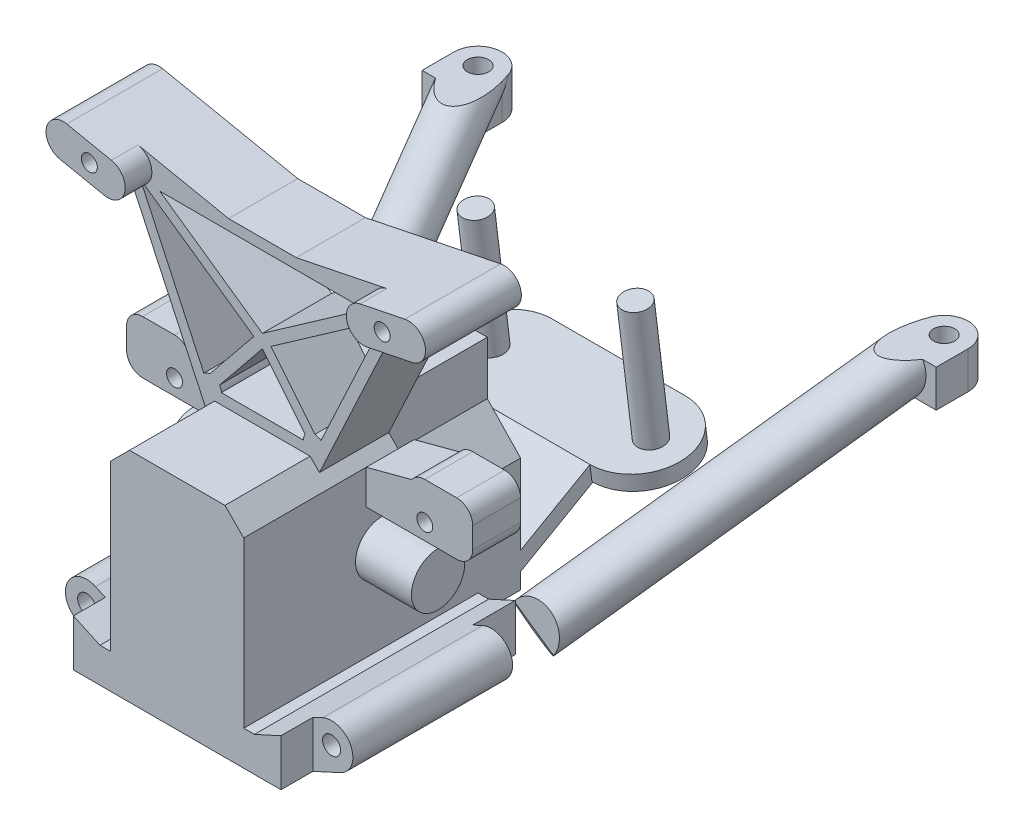
from build123d import *

# Parameters (mm, degrees)
SKETCH1_R                    = 5
DRIVELINE_AXIS_DEPTH         = 23
DUMMY_BOSS_DEPTH             = 26
PIN_BASE_DEPTH               = 44
PIN_HOLES_D                  = 3.4
SKETCH8_R                    = 1.5
UPRIGHTS_DEPTH               = 10
UPRIGHTS_DEPTH_BACK          = 3
SKETCH9_R                    = 1.5
SHOCK_MOUNT_DEPTH            = 5
SHOCK_MOUNT_DEPTH_BACK       = 13
SKETCH10_R                   = 1.5
TURNBUCKLE_MOUNTS_DEPTH      = 3
TURNBUCKLE_MOUNTS_DEPTH_BACK = 6
TURNBUCKLE_ROOM_DEPTH        = 1
TURNBUCKLE_ROOM_DEPTH_BACK   = 23
ARM_PROFILE_R                = 4.5
CHASSIS_MOUNT_DEPTH          = 7
SKETCH29_W                   = 17.866942734
SKETCH29_H                   = 5.34009454
TRIM_DEPTH                   = 50
SKETCH30_R                   = 2
CHASSIS_HOLES_DEPTH          = 7
BOSS_EXTRUDE2_DEPTH          = 12.5
BOSS_EXTRUDE3_DEPTH          = 3
SKETCH43_R                   = 2.5
BOSS_EXTRUDE4_DEPTH          = 24
SKETCH45_W                   = 10.988682225
SKETCH45_H                   = 8
CUT_EXTRUDE5_DEPTH           = 14


with BuildPart() as part:
    # Sketch1 → Driveline Axis (new body, symmetric)
    with BuildSketch(Plane(origin=(0, 0, 0), x_dir=(0, 0, -1), z_dir=(1, 0, 0))):
        Circle(SKETCH1_R)
    extrude(amount=DRIVELINE_AXIS_DEPTH, both=True)

    # Sketch2 → Dummy Boss (add, symmetric)
    with BuildSketch(Plane.XY):
        Polygon((-12.5, -20), (-12.5, 14.464466094), (-8.964466094, 18), (8.964466094, 18), (12.5, 14.464466094), (12.5, -20), align=None)
    extrude(amount=DUMMY_BOSS_DEPTH, both=True)

    # Sketch3 → Pin Base (add)
    with BuildSketch(Plane(origin=(0, 0, -18), x_dir=(-1, 0, 0), z_dir=(0, 0, -1))):
        with BuildLine():
            Line((-19.5, -23), (19.5, -23))
            Line((19.5, -23), (24.664120213, -20.637403458))
            ThreePointArc((24.664120213, -20.637403458), (26.637403458, -15.335879787), (21.335879787, -13.362596542))
            Line((21.335879787, -13.362596542), (14.5, -16.490026826))
            Line((14.5, -16.490026826), (12.5, -16.490026826))
            Line((12.5, -16.490026826), (12.5, -20))
            Line((12.5, -20), (-12.5, -20))
            Line((-12.5, -20), (-12.5, -16.490026826))
            Line((-12.5, -16.490026826), (-14.5, -16.490026826))
            Line((-14.5, -16.490026826), (-21.335879787, -13.362596542))
            ThreePointArc((-21.335879787, -13.362596542), (-26.637403458, -15.335879787), (-24.664120213, -20.637403458))
            Line((-24.664120213, -20.637403458), (-19.5, -23))
        make_face()
    extrude(amount=-PIN_BASE_DEPTH)

    # Pin Holes (through all)
    with Locations(Plane(origin=(0, 0, -18), x_dir=(-1, 0, 0), z_dir=(0, 0, -1))):
        with Locations((-23, -17), (23, -17)):
            Hole(PIN_HOLES_D / 2)

    # Sketch8 → Uprights (add, two sides)
    with BuildSketch(Plane.XY) as uprights_sk:
        with BuildLine():
            Line((-10.732233047, 16.232233047), (-24.661465898, 46.103569293))
            Line((-24.661465898, 46.103569293), (-33.048979486, 47.815663334))
            ThreePointArc((-33.048979486, 47.815663334), (-35.583316151, 51.65), (-31.748979486, 54.184336666))
            Line((-31.748979486, 54.184336666), (-6.351020514, 49))
            Line((-6.351020514, 49), (6.351020514, 49))
            Line((6.351020514, 49), (31.748979486, 54.184336666))
            ThreePointArc((31.748979486, 54.184336666), (35.583316151, 51.65), (33.048979486, 47.815663334))
            Line((33.048979486, 47.815663334), (24.661465898, 46.103569293))
            Line((24.661465898, 46.103569293), (10.732233047, 16.232233047))
            Line((10.732233047, 16.232233047), (8.964466094, 18))
            Line((8.964466094, 18), (-8.964466094, 18))
            Line((-8.964466094, 18), (-10.732233047, 16.232233047))
        make_face()
        with Locations((-27.5, 50)):
            Circle(SKETCH8_R, mode=Mode.SUBTRACT)
        with Locations((27.5, 50)):
            Circle(SKETCH8_R, mode=Mode.SUBTRACT)
        with BuildLine():
            Line((9.866245938, 21.994232403), (1.612099151, 32.1872548))
            Line((1.612099151, 32.1872548), (22.924030195, 47.110029571))
            Line((22.924030195, 47.110029571), (10.997739753, 21.534017182))
            ThreePointArc((10.997739753, 21.534017182), (10.467987263, 21.852621345), (9.866245938, 21.994232403))
        make_face(mode=Mode.SUBTRACT)
        with BuildLine():
            Line((7.714466094, 20), (-7.714466094, 20))
            ThreePointArc((-7.714466094, 20), (-7.795487149, 20.563488959), (-8.031985901, 21.081323449))
            Line((-8.031985901, 21.081323449), (0, 31))
            Line((0, 31), (8.031985901, 21.081323449))
            ThreePointArc((8.031985901, 21.081323449), (7.795487149, 20.563488959), (7.714466094, 20))
        make_face(mode=Mode.SUBTRACT)
        with BuildLine():
            Line((-10.997739753, 21.534017182), (-22.924030195, 47.110029571))
            Line((-22.924030195, 47.110029571), (-1.612099151, 32.1872548))
            Line((-1.612099151, 32.1872548), (-9.866245938, 21.994232403))
            ThreePointArc((-9.866245938, 21.994232403), (-10.467987263, 21.852621345), (-10.997739753, 21.534017182))
        make_face(mode=Mode.SUBTRACT)
        Polygon((-19.279998091, 47), (0, 33.5), (19.279998091, 47), align=None, mode=Mode.SUBTRACT)
    extrude(amount=UPRIGHTS_DEPTH)
    extrude(uprights_sk.sketch, amount=-UPRIGHTS_DEPTH_BACK)

    # Sketch9 → Shock Mount (add, two sides)
    with BuildSketch(Plane.XY.offset(10)) as shock_mount_sk:
        with BuildLine():
            Line((-24.661465898, 46.103569293), (-33.048979486, 47.815663334))
            ThreePointArc((-33.048979486, 47.815663334), (-35.583316151, 51.65), (-31.748979486, 54.184336666))
            Line((-31.748979486, 54.184336666), (-23.361465898, 52.472242624))
            ThreePointArc((-23.361465898, 52.472242624), (-20.827129232, 48.637905958), (-24.661465898, 46.103569293))
        make_face()
        with Locations((-27.5, 50)):
            Circle(SKETCH9_R, mode=Mode.SUBTRACT)
        with BuildLine():
            Line((23.361465898, 52.472242624), (31.748979486, 54.184336666))
            ThreePointArc((31.748979486, 54.184336666), (35.583316151, 51.65), (33.048979486, 47.815663334))
            Line((33.048979486, 47.815663334), (24.661465898, 46.103569293))
            ThreePointArc((24.661465898, 46.103569293), (20.827129232, 48.637905958), (23.361465898, 52.472242624))
        make_face()
        with Locations((27.5, 50)):
            Circle(SKETCH9_R, mode=Mode.SUBTRACT)
    extrude(amount=SHOCK_MOUNT_DEPTH)
    extrude(shock_mount_sk.sketch, amount=-SHOCK_MOUNT_DEPTH_BACK)

    # Sketch10 → Turnbuckle Mounts (add, two sides)
    with BuildSketch(Plane.XY) as turnbuckle_mounts_sk:
        with BuildLine():
            Line((29.5, 8), (12.5, 8))
            Line((12.5, 8), (12.5, 14.464466094))
            Line((12.5, 14.464466094), (21.055616084, 16.739249053))
            ThreePointArc((21.055616084, 16.739249053), (22.124817677, 17.666247097), (23.5, 18))
            Line((23.5, 18), (29.5, 18))
            ThreePointArc((29.5, 18), (31.621320344, 17.121320344), (32.5, 15))
            Line((32.5, 15), (32.5, 11))
            ThreePointArc((32.5, 11), (31.621320344, 8.878679656), (29.5, 8))
        make_face()
        with Locations((23.5, 11)):
            Circle(SKETCH10_R, mode=Mode.SUBTRACT)
        with BuildLine():
            Line((-12.5, 14.464466094), (-21.055616084, 16.739249053))
            ThreePointArc((-21.055616084, 16.739249053), (-22.124817677, 17.666247097), (-23.5, 18))
            Line((-23.5, 18), (-29.5, 18))
            ThreePointArc((-29.5, 18), (-31.621320344, 17.121320344), (-32.5, 15))
            Line((-32.5, 15), (-32.5, 11))
            ThreePointArc((-32.5, 11), (-31.621320344, 8.878679656), (-29.5, 8))
            Line((-29.5, 8), (-12.5, 8))
            Line((-12.5, 8), (-12.5, 14.464466094))
        make_face()
        with Locations((-23.5, 11)):
            Circle(SKETCH10_R, mode=Mode.SUBTRACT)
    extrude(amount=TURNBUCKLE_MOUNTS_DEPTH)
    extrude(turnbuckle_mounts_sk.sketch, amount=-TURNBUCKLE_MOUNTS_DEPTH_BACK)

    # Sketch11 → Turnbuckle Room (cut, two sides)
    with BuildSketch(Plane(origin=(0, 0, -26), x_dir=(-1, 0, 0), z_dir=(0, 0, -1))) as turnbuckle_room_sk:
        Polygon((8.964466094, 18), (5.75, 18), (5.75, 8), (12.5, 1.544903812), (12.5, 14.464466094), align=None)
        Polygon((-12.5, 14.464466094), (-12.5, 1.464466094), (-6.25, 8), (-6.25, 18), (-8.964466094, 18), align=None)
    extrude(amount=TURNBUCKLE_ROOM_DEPTH, mode=Mode.SUBTRACT)
    extrude(turnbuckle_room_sk.sketch, amount=-TURNBUCKLE_ROOM_DEPTH_BACK, mode=Mode.SUBTRACT)

    # Arm: sweep along a path in Sketch13
    with BuildLine(Plane(origin=(14.391793376, 0, 5.313892939), x_dir=(0.346374083, 0, -0.938096474), z_dir=(0.938096474, 0, 0.346374083))) as arm_path:
        Line((24.852340438, -17), (84.852340438, 13))
    # Arm profile (on start of the path) → Arm (sweep)
    with BuildSketch(Plane(origin=(23, -17, -18), x_dir=(0, -0.88247717, -0.470355232), z_dir=(0.309806398, 0.447213595, -0.839058994))):
        Circle(ARM_PROFILE_R)
    arm = sweep(path=arm_path.line)

    # Mirror1: Arm across plane
    add(arm.mirror(Plane(origin=(0, 0, 0), x_dir=(0, 0, 1), z_dir=(1, 0, 0))))

    # Sketch28 → Chassis mount (add)
    with BuildSketch(Plane(origin=(0, 13, 0), x_dir=(-1, 0, 0), z_dir=(0, -1, 0))):
        with BuildLine():
            Line((-39.282444966, 74.285788448), (-39.282444966, 68.285788448))
            Line((-39.282444966, 68.285788448), (-48.282444966, 68.285788448))
            Line((-48.282444966, 68.285788448), (-48.282444966, 74.285788448))
            ThreePointArc((-48.282444966, 74.285788448), (-43.782444966, 78.785788448), (-39.282444966, 74.285788448))
        make_face()
    chassis_mount = extrude(amount=CHASSIS_MOUNT_DEPTH)

    # Mirror2: Chassis mount across plane
    add(chassis_mount.mirror(Plane(origin=(0, 0, 0), x_dir=(0, 0, 1), z_dir=(1, 0, 0))))

    # Sketch29 → Trim (cut, symmetric)
    with BuildSketch(Plane(origin=(0, 0, 0), x_dir=(0, 0, -1), z_dir=(1, 0, 0))):
        with Locations((69.852317081, 15.67004727)):
            Rectangle(SKETCH29_W, SKETCH29_H)
    extrude(amount=TRIM_DEPTH, both=True, mode=Mode.SUBTRACT)

    # Sketch30 → Chassis Holes (cut)
    with BuildSketch(Plane(origin=(0, 13, 0), x_dir=(-1, 0, 0), z_dir=(0, -1, 0))):
        with Locations((-43.782444966, 74.285788448)):
            Circle(SKETCH30_R)
    chassis_holes = extrude(amount=CHASSIS_HOLES_DEPTH, mode=Mode.SUBTRACT)

    # Mirror3: Chassis Holes across plane
    add(chassis_holes.mirror(Plane(origin=(0, 0, 0), x_dir=(0, 0, 1), z_dir=(1, 0, 0))), mode=Mode.SUBTRACT)

    # Sketch40 → Boss-Extrude2 (add, symmetric)
    with BuildSketch(Plane(origin=(0, 0, 0), x_dir=(0, 0, -1), z_dir=(1, 0, 0))):
        Polygon((26, -13.545257512), (39.035885991, -6.100654803), (56.964114009, -3.899345197), (56.964114009, -6.921874674), (40, -9.004805964), (26, -17), align=None)
    extrude(amount=BOSS_EXTRUDE2_DEPTH, both=True)

    # Sketch41 → Boss-Extrude3 (add)
    with BuildSketch(Plane(origin=(0, -10.73186481, -1.317707308), x_dir=(1, 0, 0), z_dir=(0, 0.992546152, 0.121869343))):
        with BuildLine():
            Line((12.5, 56.064301503), (12.5, 38.001435621))
            ThreePointArc((12.5, 38.001435621), (21.531432941, 47.032868562), (12.5, 56.064301503))
        make_face()
    boss_extrude3 = extrude(amount=-BOSS_EXTRUDE3_DEPTH)

    # Mirror4: Boss-Extrude3 across plane
    add(boss_extrude3.mirror(Plane(origin=(0, 0, 0), x_dir=(0, 0, 1), z_dir=(1, 0, 0))))

    # Sketch43 → Boss-Extrude4 (add)
    with BuildSketch(Plane(origin=(0, -10.73186481, -1.317707308), x_dir=(1, 0, 0), z_dir=(0, 0.992546152, 0.121869343))):
        with Locations((-15, 47.032868562)):
            Circle(SKETCH43_R)
        with Locations((15, 47.032868562)):
            Circle(SKETCH43_R)
    extrude(amount=BOSS_EXTRUDE4_DEPTH)

    # Sketch45 → Cut-Extrude5 (cut)
    with BuildSketch(Plane.XZ.offset(23)):
        with Locations((24.994341113, -14)):
            Rectangle(SKETCH45_W, SKETCH45_H)
        with Locations((24.994341113, 24)):
            Rectangle(SKETCH45_W, SKETCH45_H)
        with Locations((-24.994341113, 24)):
            Rectangle(SKETCH45_W, SKETCH45_H)
        with Locations((-24.994341113, -14)):
            Rectangle(SKETCH45_W, SKETCH45_H)
    extrude(amount=-CUT_EXTRUDE5_DEPTH, mode=Mode.SUBTRACT)


solid = part.part
